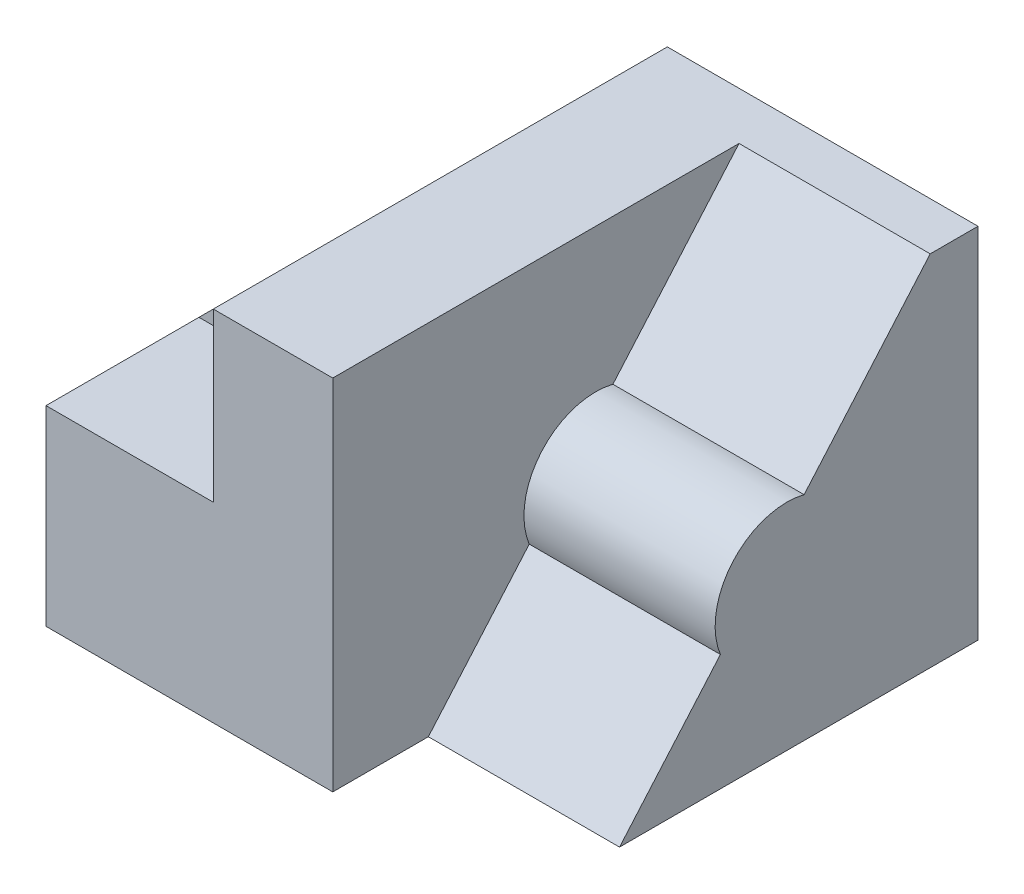
from build123d import *

# Parameters (mm, degrees)
SKETCH1_W           = 95
SKETCH1_H           = 75
BOSS_EXTRUDE1_DEPTH = 100
CUT_EXTRUDE1_DEPTH  = 40
SKETCH4_W           = 35
SKETCH4_H           = 35
CUT_EXTRUDE2_DEPTH  = 96
BOSS_EXTRUDE4_DEPTH = 6


with BuildPart() as part:
    # Sketch1 → Boss-Extrude1 (new body)
    with BuildSketch(Plane(origin=(0, 0, 0), x_dir=(0, 0, -1), z_dir=(1, 0, 0))):
        Rectangle(SKETCH1_W, SKETCH1_H)
    extrude(amount=BOSS_EXTRUDE1_DEPTH)

    # Sketch2 → Cut-Extrude1 (cut)
    with BuildSketch(Plane(origin=(100, 0, 0), x_dir=(0, 0, -1), z_dir=(1, 0, 0))):
        with BuildLine():
            Line((37.5, 37.5), (11.116502976, 7.057503434))
            ThreePointArc((11.116502976, 7.057503434), (-3.835336242, 2.323958076), (-6.395690793, -13.148873992))
            Line((-6.395690793, -13.148873992), (-27.5, -37.5))
            Line((-27.5, -37.5), (-47.5, -37.5))
            Line((-47.5, -37.5), (-47.5, 37.5))
            Line((-47.5, 37.5), (37.5, 37.5))
        make_face()
    extrude(amount=-CUT_EXTRUDE1_DEPTH, mode=Mode.SUBTRACT)

    # Sketch4 → Cut-Extrude2 (cut, through all)
    with BuildSketch(Plane.XY.offset(47.5)):
        with Locations((17.5, 20)):
            Rectangle(SKETCH4_W, SKETCH4_H)
    extrude(amount=-CUT_EXTRUDE2_DEPTH, mode=Mode.SUBTRACT)

    # Sketch14 → Boss-Extrude4 (add)
    with BuildSketch(Plane.XY.offset(9.5)):
        Polygon((35, 37.5), (0, 2.5), (35, 2.5), align=None)
    extrude(amount=BOSS_EXTRUDE4_DEPTH)


solid = part.part
